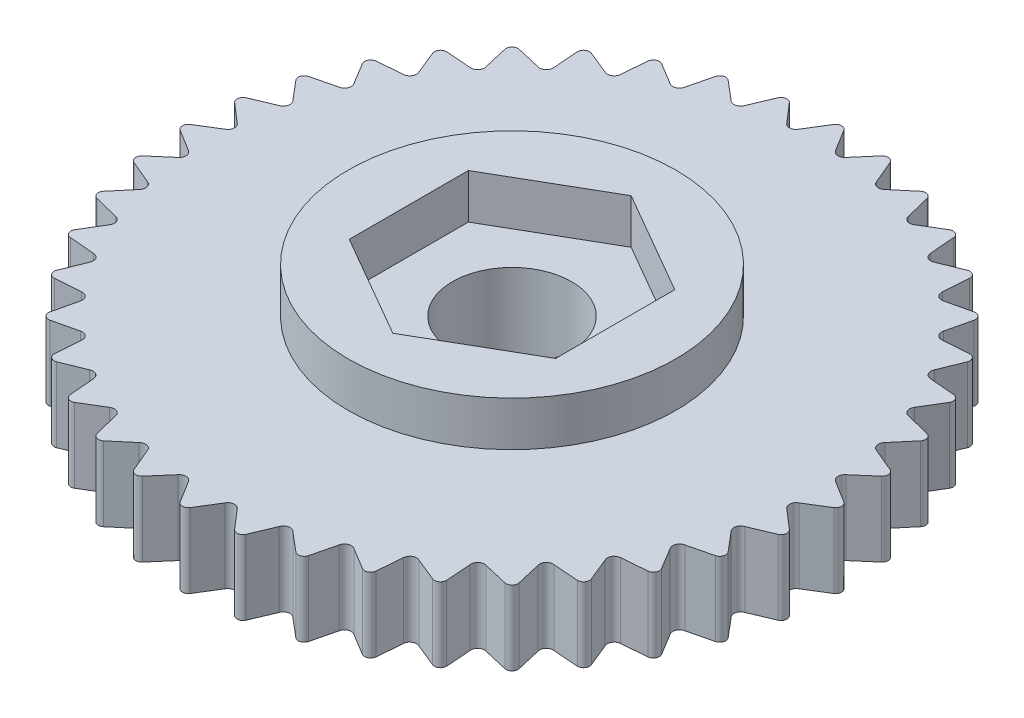
from build123d import *

# Parameters (mm, degrees)
SKETCH1_R           = 5.5
BOSS_EXTRUDE1_DEPTH = 2.5
SKETCH2_R           = 5.5
BOSS_EXTRUDE2_DEPTH = 4
SKETCH3_R           = 2.0025
BOSS_EXTRUDE3_DEPTH = 2.5


with BuildPart() as part:
    # Sketch1 → Boss-Extrude1 (new body)
    with BuildSketch(Plane(origin=(0, 0, 0), x_dir=(1, 0, 0), z_dir=(0, 1, 0))):
        with BuildLine():
            ThreePointArc((0.168753863, 10.978113748), (0, 11.07041569), (-0.168753863, 10.978113748))
            Line((-0.168753863, 10.978113748), (-0.617006311, 10.255915893))
            ThreePointArc((-0.617006311, 10.255915893), (-0.623950042, 10.243921028), (-0.63161743, 10.232375321))
            ThreePointArc((-0.63161743, 10.232375321), (-0.704256465, 10.166709543), (-0.797879357, 10.138018468))
            ThreePointArc((-0.797879357, 10.138018468), (-0.907657674, 10.156977793), (-0.994968777, 10.226169602))
            Line((-0.994968777, 10.226169602), (-1.550679129, 10.869353871))
            ThreePointArc((-1.550679129, 10.869353871), (-1.731794556, 10.934120503), (-1.884031574, 10.816556031))
            Line((-1.884031574, 10.816556031), (-2.213788656, 10.033127497))
            ThreePointArc((-2.213788656, 10.033127497), (-2.218770487, 10.02019407), (-2.224537331, 10.007591067))
            ThreePointArc((-2.224537331, 10.007591067), (-2.286009668, 9.931370495), (-2.373991634, 9.888386807))
            ThreePointArc((-2.373991634, 9.888386807), (-2.48538429, 9.889939599), (-2.582444431, 9.944621076))
            Line((-2.582444431, 9.944621076), (-3.231929254, 10.492954429))
            ThreePointArc((-3.231929254, 10.492954429), (-3.420946583, 10.52859098), (-3.552918175, 10.388658806))
            Line((-3.552918175, 10.388658806), (-3.756060176, 9.563290205))
            ThreePointArc((-3.756060176, 9.563290205), (-3.75895744, 9.549736679), (-3.76268174, 9.536386707))
            ThreePointArc((-3.76268174, 9.536386707), (-3.811473726, 9.451488144), (-3.891648358, 9.395270245))
            ThreePointArc((-3.891648358, 9.395270245), (-4.001912495, 9.37937827), (-4.106331733, 9.418202975))
            Line((-4.106331733, 9.418202975), (-4.833598554, 9.858183624))
            ThreePointArc((-4.833598554, 9.858183624), (-5.025863551, 9.863812605), (-5.13432014, 9.704958323))
            Line((-5.13432014, 9.704958323), (-5.20584503, 8.857972969))
            ThreePointArc((-5.20584503, 8.857972969), (-5.206586385, 8.844133078), (-5.208176436, 8.830364857))
            ThreePointArc((-5.208176436, 8.830364857), (-5.243086651, 8.738878788), (-5.313479783, 8.670810949))
            ThreePointArc((-5.313479783, 8.670810949), (-5.419900334, 8.637865519), (-5.529107519, 8.65987746))
            Line((-5.529107519, 8.65987746), (-6.316248616, 8.980671621))
            ThreePointArc((-6.316248616, 8.980671621), (-6.507027079, 8.956154428), (-6.589298102, 8.782289557))
            Line((-6.589298102, 8.782289557), (-6.527444702, 7.93454304))
            ThreePointArc((-6.527444702, 7.93454304), (-6.526011893, 7.920757568), (-6.525428545, 7.906910117))
            ThreePointArc((-6.525428545, 7.906910117), (-6.545597382, 7.811089234), (-6.604475702, 7.73284751))
            ThreePointArc((-6.604475702, 7.73284751), (-6.704432238, 7.683659851), (-6.815738329, 7.688317022))
            Line((-6.815738329, 7.688317022), (-7.643371675, 7.882025677))
            ThreePointArc((-7.643371675, 7.882025677), (-7.827966005, 7.827966005), (-7.882025677, 7.643371675))
            Line((-7.882025677, 7.643371675), (-7.688317022, 6.815738329))
            ThreePointArc((-7.688317022, 6.815738329), (-7.68474533, 6.802346719), (-7.682002945, 6.78876101))
            ThreePointArc((-7.682002945, 6.78876101), (-7.686933782, 6.690964738), (-7.73284751, 6.604475702))
            ThreePointArc((-7.73284751, 6.604475702), (-7.823878771, 6.540256977), (-7.93454304, 6.527444702))
            Line((-7.93454304, 6.527444702), (-8.782289557, 6.589298102))
            ThreePointArc((-8.782289557, 6.589298102), (-8.956154428, 6.507027079), (-8.980671621, 6.316248616))
            Line((-8.980671621, 6.316248616), (-8.65987746, 5.529107519))
            ThreePointArc((-8.65987746, 5.529107519), (-8.654254833, 5.516439518), (-8.649420938, 5.503450075))
            ThreePointArc((-8.649420938, 5.503450075), (-8.638992361, 5.406086486), (-8.670810949, 5.313479783))
            ThreePointArc((-8.670810949, 5.313479783), (-8.750675441, 5.235811271), (-8.857972969, 5.20584503))
            Line((-8.857972969, 5.20584503), (-9.704958323, 5.13432014))
            ThreePointArc((-9.704958323, 5.13432014), (-9.863812605, 5.025863551), (-9.858183624, 4.833598554))
            Line((-9.858183624, 4.833598554), (-9.418202975, 4.106331733))
            ThreePointArc((-9.418202975, 4.106331733), (-9.41066786, 4.094699269), (-9.403861482, 4.082625935))
            ThreePointArc((-9.403861482, 4.082625935), (-9.378330277, 3.988092441), (-9.395270245, 3.891648358))
            ThreePointArc((-9.395270245, 3.891648358), (-9.462001441, 3.802442515), (-9.563290205, 3.756060176))
            Line((-9.563290205, 3.756060176), (-10.388658806, 3.552918175))
            ThreePointArc((-10.388658806, 3.552918175), (-10.52859098, 3.420946583), (-10.492954429, 3.231929254))
            Line((-10.492954429, 3.231929254), (-9.944621076, 2.582444431))
            ThreePointArc((-9.944621076, 2.582444431), (-9.935359013, 2.572133934), (-9.926747746, 2.561273995))
            ThreePointArc((-9.926747746, 2.561273995), (-9.886742576, 2.471898326), (-9.888386807, 2.373991634))
            ThreePointArc((-9.888386807, 2.373991634), (-9.940341563, 2.275445004), (-10.033127497, 2.213788656))
            Line((-10.033127497, 2.213788656), (-10.816556031, 1.884031574))
            ThreePointArc((-10.816556031, 1.884031574), (-10.934120503, 1.731794556), (-10.869353871, 1.550679129))
            Line((-10.869353871, 1.550679129), (-10.226169602, 0.994968777))
            ThreePointArc((-10.226169602, 0.994968777), (-10.215408652, 0.986234125), (-10.205204536, 0.976854988))
            ThreePointArc((-10.205204536, 0.976854988), (-10.151710461, 0.89483787), (-10.138018468, 0.797879357))
            ThreePointArc((-10.138018468, 0.797879357), (-10.173917485, 0.692418485), (-10.255915893, 0.617006311))
            Line((-10.255915893, 0.617006311), (-10.978113748, 0.168753863))
            ThreePointArc((-10.978113748, 0.168753863), (-11.07041569, 0), (-10.978113748, -0.168753863))
            Line((-10.978113748, -0.168753863), (-10.255915893, -0.617006311))
            ThreePointArc((-10.255915893, -0.617006311), (-10.243921028, -0.623950042), (-10.232375321, -0.63161743))
            ThreePointArc((-10.232375321, -0.63161743), (-10.166709543, -0.704256465), (-10.138018468, -0.797879357))
            ThreePointArc((-10.138018468, -0.797879357), (-10.156977793, -0.907657674), (-10.226169602, -0.994968777))
            Line((-10.226169602, -0.994968777), (-10.869353871, -1.550679129))
            ThreePointArc((-10.869353871, -1.550679129), (-10.934120503, -1.731794556), (-10.816556031, -1.884031574))
            Line((-10.816556031, -1.884031574), (-10.033127497, -2.213788656))
            ThreePointArc((-10.033127497, -2.213788656), (-10.02019407, -2.218770487), (-10.007591067, -2.224537331))
            ThreePointArc((-10.007591067, -2.224537331), (-9.931370495, -2.286009668), (-9.888386807, -2.373991634))
            ThreePointArc((-9.888386807, -2.373991634), (-9.889939599, -2.48538429), (-9.944621076, -2.582444431))
            Line((-9.944621076, -2.582444431), (-10.492954429, -3.231929254))
            ThreePointArc((-10.492954429, -3.231929254), (-10.52859098, -3.420946583), (-10.388658806, -3.552918175))
            Line((-10.388658806, -3.552918175), (-9.563290205, -3.756060176))
            ThreePointArc((-9.563290205, -3.756060176), (-9.549736679, -3.75895744), (-9.536386707, -3.76268174))
            ThreePointArc((-9.536386707, -3.76268174), (-9.451488144, -3.811473726), (-9.395270245, -3.891648358))
            ThreePointArc((-9.395270245, -3.891648358), (-9.37937827, -4.001912495), (-9.418202975, -4.106331733))
            Line((-9.418202975, -4.106331733), (-9.858183624, -4.833598554))
            ThreePointArc((-9.858183624, -4.833598554), (-9.863812605, -5.025863551), (-9.704958323, -5.13432014))
            Line((-9.704958323, -5.13432014), (-8.857972969, -5.20584503))
            ThreePointArc((-8.857972969, -5.20584503), (-8.844133078, -5.206586385), (-8.830364857, -5.208176436))
            ThreePointArc((-8.830364857, -5.208176436), (-8.738878788, -5.243086651), (-8.670810949, -5.313479783))
            ThreePointArc((-8.670810949, -5.313479783), (-8.637865519, -5.419900334), (-8.65987746, -5.529107519))
            Line((-8.65987746, -5.529107519), (-8.980671621, -6.316248616))
            ThreePointArc((-8.980671621, -6.316248616), (-8.956154428, -6.507027079), (-8.782289557, -6.589298102))
            Line((-8.782289557, -6.589298102), (-7.93454304, -6.527444702))
            ThreePointArc((-7.93454304, -6.527444702), (-7.920757568, -6.526011893), (-7.906910117, -6.525428545))
            ThreePointArc((-7.906910117, -6.525428545), (-7.811089234, -6.545597382), (-7.73284751, -6.604475702))
            ThreePointArc((-7.73284751, -6.604475702), (-7.683659851, -6.704432238), (-7.688317022, -6.815738329))
            Line((-7.688317022, -6.815738329), (-7.882025677, -7.643371675))
            ThreePointArc((-7.882025677, -7.643371675), (-7.827966005, -7.827966005), (-7.643371675, -7.882025677))
            Line((-7.643371675, -7.882025677), (-6.815738329, -7.688317022))
            ThreePointArc((-6.815738329, -7.688317022), (-6.802346719, -7.68474533), (-6.78876101, -7.682002945))
            ThreePointArc((-6.78876101, -7.682002945), (-6.690964738, -7.686933782), (-6.604475702, -7.73284751))
            ThreePointArc((-6.604475702, -7.73284751), (-6.540256977, -7.823878771), (-6.527444702, -7.93454304))
            Line((-6.527444702, -7.93454304), (-6.589298102, -8.782289557))
            ThreePointArc((-6.589298102, -8.782289557), (-6.507027079, -8.956154428), (-6.316248616, -8.980671621))
            Line((-6.316248616, -8.980671621), (-5.529107519, -8.65987746))
            ThreePointArc((-5.529107519, -8.65987746), (-5.516439518, -8.654254833), (-5.503450075, -8.649420938))
            ThreePointArc((-5.503450075, -8.649420938), (-5.406086486, -8.638992361), (-5.313479783, -8.670810949))
            ThreePointArc((-5.313479783, -8.670810949), (-5.235811271, -8.750675441), (-5.20584503, -8.857972969))
            Line((-5.20584503, -8.857972969), (-5.13432014, -9.704958323))
            ThreePointArc((-5.13432014, -9.704958323), (-5.025863551, -9.863812605), (-4.833598554, -9.858183624))
            Line((-4.833598554, -9.858183624), (-4.106331733, -9.418202975))
            ThreePointArc((-4.106331733, -9.418202975), (-4.094699269, -9.41066786), (-4.082625935, -9.403861482))
            ThreePointArc((-4.082625935, -9.403861482), (-3.988092441, -9.378330277), (-3.891648358, -9.395270245))
            ThreePointArc((-3.891648358, -9.395270245), (-3.802442515, -9.462001441), (-3.756060176, -9.563290205))
            Line((-3.756060176, -9.563290205), (-3.552918175, -10.388658806))
            ThreePointArc((-3.552918175, -10.388658806), (-3.420946583, -10.52859098), (-3.231929254, -10.492954429))
            Line((-3.231929254, -10.492954429), (-2.582444431, -9.944621076))
            ThreePointArc((-2.582444431, -9.944621076), (-2.572133934, -9.935359013), (-2.561273995, -9.926747746))
            ThreePointArc((-2.561273995, -9.926747746), (-2.471898326, -9.886742576), (-2.373991634, -9.888386807))
            ThreePointArc((-2.373991634, -9.888386807), (-2.275445004, -9.940341563), (-2.213788656, -10.033127497))
            Line((-2.213788656, -10.033127497), (-1.884031574, -10.816556031))
            ThreePointArc((-1.884031574, -10.816556031), (-1.731794556, -10.934120503), (-1.550679129, -10.869353871))
            Line((-1.550679129, -10.869353871), (-0.994968777, -10.226169602))
            ThreePointArc((-0.994968777, -10.226169602), (-0.986234125, -10.215408652), (-0.976854988, -10.205204536))
            ThreePointArc((-0.976854988, -10.205204536), (-0.89483787, -10.151710461), (-0.797879357, -10.138018468))
            ThreePointArc((-0.797879357, -10.138018468), (-0.692418485, -10.173917485), (-0.617006311, -10.255915893))
            Line((-0.617006311, -10.255915893), (-0.168753863, -10.978113748))
            ThreePointArc((-0.168753863, -10.978113748), (0, -11.07041569), (0.168753863, -10.978113748))
            Line((0.168753863, -10.978113748), (0.617006311, -10.255915893))
            ThreePointArc((0.617006311, -10.255915893), (0.623950042, -10.243921028), (0.63161743, -10.232375321))
            ThreePointArc((0.63161743, -10.232375321), (0.704256465, -10.166709543), (0.797879357, -10.138018468))
            ThreePointArc((0.797879357, -10.138018468), (0.907657674, -10.156977793), (0.994968777, -10.226169602))
            Line((0.994968777, -10.226169602), (1.550679129, -10.869353871))
            ThreePointArc((1.550679129, -10.869353871), (1.731794556, -10.934120503), (1.884031574, -10.816556031))
            Line((1.884031574, -10.816556031), (2.213788656, -10.033127497))
            ThreePointArc((2.213788656, -10.033127497), (2.218770487, -10.02019407), (2.224537331, -10.007591067))
            ThreePointArc((2.224537331, -10.007591067), (2.286009668, -9.931370495), (2.373991634, -9.888386807))
            ThreePointArc((2.373991634, -9.888386807), (2.48538429, -9.889939599), (2.582444431, -9.944621076))
            Line((2.582444431, -9.944621076), (3.231929254, -10.492954429))
            ThreePointArc((3.231929254, -10.492954429), (3.420946583, -10.52859098), (3.552918175, -10.388658806))
            Line((3.552918175, -10.388658806), (3.756060176, -9.563290205))
            ThreePointArc((3.756060176, -9.563290205), (3.75895744, -9.549736679), (3.76268174, -9.536386707))
            ThreePointArc((3.76268174, -9.536386707), (3.811473726, -9.451488144), (3.891648358, -9.395270245))
            ThreePointArc((3.891648358, -9.395270245), (4.001912495, -9.37937827), (4.106331733, -9.418202975))
            Line((4.106331733, -9.418202975), (4.833598554, -9.858183624))
            ThreePointArc((4.833598554, -9.858183624), (5.025863551, -9.863812605), (5.13432014, -9.704958323))
            Line((5.13432014, -9.704958323), (5.20584503, -8.857972969))
            ThreePointArc((5.20584503, -8.857972969), (5.206586385, -8.844133078), (5.208176436, -8.830364857))
            ThreePointArc((5.208176436, -8.830364857), (5.243086651, -8.738878788), (5.313479783, -8.670810949))
            ThreePointArc((5.313479783, -8.670810949), (5.419900334, -8.637865519), (5.529107519, -8.65987746))
            Line((5.529107519, -8.65987746), (6.316248616, -8.980671621))
            ThreePointArc((6.316248616, -8.980671621), (6.507027079, -8.956154428), (6.589298102, -8.782289557))
            Line((6.589298102, -8.782289557), (6.527444702, -7.93454304))
            ThreePointArc((6.527444702, -7.93454304), (6.526011893, -7.920757568), (6.525428545, -7.906910117))
            ThreePointArc((6.525428545, -7.906910117), (6.545597382, -7.811089234), (6.604475702, -7.73284751))
            ThreePointArc((6.604475702, -7.73284751), (6.704432238, -7.683659851), (6.815738329, -7.688317022))
            Line((6.815738329, -7.688317022), (7.643371675, -7.882025677))
            ThreePointArc((7.643371675, -7.882025677), (7.827966005, -7.827966005), (7.882025677, -7.643371675))
            Line((7.882025677, -7.643371675), (7.688317022, -6.815738329))
            ThreePointArc((7.688317022, -6.815738329), (7.68474533, -6.802346719), (7.682002945, -6.78876101))
            ThreePointArc((7.682002945, -6.78876101), (7.686933782, -6.690964738), (7.73284751, -6.604475702))
            ThreePointArc((7.73284751, -6.604475702), (7.823878771, -6.540256977), (7.93454304, -6.527444702))
            Line((7.93454304, -6.527444702), (8.782289557, -6.589298102))
            ThreePointArc((8.782289557, -6.589298102), (8.956154428, -6.507027079), (8.980671621, -6.316248616))
            Line((8.980671621, -6.316248616), (8.65987746, -5.529107519))
            ThreePointArc((8.65987746, -5.529107519), (8.654254833, -5.516439518), (8.649420938, -5.503450075))
            ThreePointArc((8.649420938, -5.503450075), (8.638992361, -5.406086486), (8.670810949, -5.313479783))
            ThreePointArc((8.670810949, -5.313479783), (8.750675441, -5.235811271), (8.857972969, -5.20584503))
            Line((8.857972969, -5.20584503), (9.704958323, -5.13432014))
            ThreePointArc((9.704958323, -5.13432014), (9.863812605, -5.025863551), (9.858183624, -4.833598554))
            Line((9.858183624, -4.833598554), (9.418202975, -4.106331733))
            ThreePointArc((9.418202975, -4.106331733), (9.41066786, -4.094699269), (9.403861482, -4.082625935))
            ThreePointArc((9.403861482, -4.082625935), (9.378330277, -3.988092441), (9.395270245, -3.891648358))
            ThreePointArc((9.395270245, -3.891648358), (9.462001441, -3.802442515), (9.563290205, -3.756060176))
            Line((9.563290205, -3.756060176), (10.388658806, -3.552918175))
            ThreePointArc((10.388658806, -3.552918175), (10.52859098, -3.420946583), (10.492954429, -3.231929254))
            Line((10.492954429, -3.231929254), (9.944621076, -2.582444431))
            ThreePointArc((9.944621076, -2.582444431), (9.935359013, -2.572133934), (9.926747746, -2.561273995))
            ThreePointArc((9.926747746, -2.561273995), (9.886742576, -2.471898326), (9.888386807, -2.373991634))
            ThreePointArc((9.888386807, -2.373991634), (9.940341563, -2.275445004), (10.033127497, -2.213788656))
            Line((10.033127497, -2.213788656), (10.816556031, -1.884031574))
            ThreePointArc((10.816556031, -1.884031574), (10.934120503, -1.731794556), (10.869353871, -1.550679129))
            Line((10.869353871, -1.550679129), (10.226169602, -0.994968777))
            ThreePointArc((10.226169602, -0.994968777), (10.215408652, -0.986234125), (10.205204536, -0.976854988))
            ThreePointArc((10.205204536, -0.976854988), (10.151710461, -0.89483787), (10.138018468, -0.797879357))
            ThreePointArc((10.138018468, -0.797879357), (10.173917485, -0.692418485), (10.255915893, -0.617006311))
            Line((10.255915893, -0.617006311), (10.978113748, -0.168753863))
            ThreePointArc((10.978113748, -0.168753863), (11.07041569, 0), (10.978113748, 0.168753863))
            Line((10.978113748, 0.168753863), (10.255915893, 0.617006311))
            ThreePointArc((10.255915893, 0.617006311), (10.243921028, 0.623950042), (10.232375321, 0.63161743))
            ThreePointArc((10.232375321, 0.63161743), (10.166709543, 0.704256465), (10.138018468, 0.797879357))
            ThreePointArc((10.138018468, 0.797879357), (10.156977793, 0.907657674), (10.226169602, 0.994968777))
            Line((10.226169602, 0.994968777), (10.869353871, 1.550679129))
            ThreePointArc((10.869353871, 1.550679129), (10.934120503, 1.731794556), (10.816556031, 1.884031574))
            Line((10.816556031, 1.884031574), (10.033127497, 2.213788656))
            ThreePointArc((10.033127497, 2.213788656), (10.02019407, 2.218770487), (10.007591067, 2.224537331))
            ThreePointArc((10.007591067, 2.224537331), (9.931370495, 2.286009668), (9.888386807, 2.373991634))
            ThreePointArc((9.888386807, 2.373991634), (9.889939599, 2.48538429), (9.944621076, 2.582444431))
            Line((9.944621076, 2.582444431), (10.492954429, 3.231929254))
            ThreePointArc((10.492954429, 3.231929254), (10.52859098, 3.420946583), (10.388658806, 3.552918175))
            Line((10.388658806, 3.552918175), (9.563290205, 3.756060176))
            ThreePointArc((9.563290205, 3.756060176), (9.549736679, 3.75895744), (9.536386707, 3.76268174))
            ThreePointArc((9.536386707, 3.76268174), (9.451488144, 3.811473726), (9.395270245, 3.891648358))
            ThreePointArc((9.395270245, 3.891648358), (9.37937827, 4.001912495), (9.418202975, 4.106331733))
            Line((9.418202975, 4.106331733), (9.858183624, 4.833598554))
            ThreePointArc((9.858183624, 4.833598554), (9.863812605, 5.025863551), (9.704958323, 5.13432014))
            Line((9.704958323, 5.13432014), (8.857972969, 5.20584503))
            ThreePointArc((8.857972969, 5.20584503), (8.844133078, 5.206586385), (8.830364857, 5.208176436))
            ThreePointArc((8.830364857, 5.208176436), (8.738878788, 5.243086651), (8.670810949, 5.313479783))
            ThreePointArc((8.670810949, 5.313479783), (8.637865519, 5.419900334), (8.65987746, 5.529107519))
            Line((8.65987746, 5.529107519), (8.980671621, 6.316248616))
            ThreePointArc((8.980671621, 6.316248616), (8.956154428, 6.507027079), (8.782289557, 6.589298102))
            Line((8.782289557, 6.589298102), (7.93454304, 6.527444702))
            ThreePointArc((7.93454304, 6.527444702), (7.920757568, 6.526011893), (7.906910117, 6.525428545))
            ThreePointArc((7.906910117, 6.525428545), (7.811089234, 6.545597382), (7.73284751, 6.604475702))
            ThreePointArc((7.73284751, 6.604475702), (7.683659851, 6.704432238), (7.688317022, 6.815738329))
            Line((7.688317022, 6.815738329), (7.882025677, 7.643371675))
            ThreePointArc((7.882025677, 7.643371675), (7.827966005, 7.827966005), (7.643371675, 7.882025677))
            Line((7.643371675, 7.882025677), (6.815738329, 7.688317022))
            ThreePointArc((6.815738329, 7.688317022), (6.802346719, 7.68474533), (6.78876101, 7.682002945))
            ThreePointArc((6.78876101, 7.682002945), (6.690964738, 7.686933782), (6.604475702, 7.73284751))
            ThreePointArc((6.604475702, 7.73284751), (6.540256977, 7.823878771), (6.527444702, 7.93454304))
            Line((6.527444702, 7.93454304), (6.589298102, 8.782289557))
            ThreePointArc((6.589298102, 8.782289557), (6.507027079, 8.956154428), (6.316248616, 8.980671621))
            Line((6.316248616, 8.980671621), (5.529107519, 8.65987746))
            ThreePointArc((5.529107519, 8.65987746), (5.516439518, 8.654254833), (5.503450075, 8.649420938))
            ThreePointArc((5.503450075, 8.649420938), (5.406086486, 8.638992361), (5.313479783, 8.670810949))
            ThreePointArc((5.313479783, 8.670810949), (5.235811271, 8.750675441), (5.20584503, 8.857972969))
            Line((5.20584503, 8.857972969), (5.13432014, 9.704958323))
            ThreePointArc((5.13432014, 9.704958323), (5.025863551, 9.863812605), (4.833598554, 9.858183624))
            Line((4.833598554, 9.858183624), (4.106331733, 9.418202975))
            ThreePointArc((4.106331733, 9.418202975), (4.094699269, 9.41066786), (4.082625935, 9.403861482))
            ThreePointArc((4.082625935, 9.403861482), (3.988092441, 9.378330277), (3.891648358, 9.395270245))
            ThreePointArc((3.891648358, 9.395270245), (3.802442515, 9.462001441), (3.756060176, 9.563290205))
            Line((3.756060176, 9.563290205), (3.552918175, 10.388658806))
            ThreePointArc((3.552918175, 10.388658806), (3.420946583, 10.52859098), (3.231929254, 10.492954429))
            Line((3.231929254, 10.492954429), (2.582444431, 9.944621076))
            ThreePointArc((2.582444431, 9.944621076), (2.572133934, 9.935359013), (2.561273995, 9.926747746))
            ThreePointArc((2.561273995, 9.926747746), (2.471898326, 9.886742576), (2.373991634, 9.888386807))
            ThreePointArc((2.373991634, 9.888386807), (2.275445004, 9.940341563), (2.213788656, 10.033127497))
            Line((2.213788656, 10.033127497), (1.884031574, 10.816556031))
            ThreePointArc((1.884031574, 10.816556031), (1.731794556, 10.934120503), (1.550679129, 10.869353871))
            Line((1.550679129, 10.869353871), (0.994968777, 10.226169602))
            ThreePointArc((0.994968777, 10.226169602), (0.986234125, 10.215408652), (0.976854988, 10.205204536))
            ThreePointArc((0.976854988, 10.205204536), (0.89483787, 10.151710461), (0.797879357, 10.138018468))
            ThreePointArc((0.797879357, 10.138018468), (0.692418485, 10.173917485), (0.617006311, 10.255915893))
            Line((0.617006311, 10.255915893), (0.168753863, 10.978113748))
        make_face()
        Circle(SKETCH1_R, mode=Mode.SUBTRACT)
    extrude(amount=BOSS_EXTRUDE1_DEPTH)

    # Sketch2 → Boss-Extrude2 (add)
    with BuildSketch(Plane(origin=(0, 0, 0), x_dir=(1, 0, 0), z_dir=(0, 1, 0))):
        Circle(SKETCH2_R)
        Polygon((0, 4.0025), (-3.466266679, 2.00125), (-3.466266679, -2.00125), (0, -4.0025), (3.466266679, -2.00125), (3.466266679, 2.00125), align=None, mode=Mode.SUBTRACT)
    extrude(amount=BOSS_EXTRUDE2_DEPTH)

    # Sketch3 → Boss-Extrude3 (add)
    with BuildSketch(Plane(origin=(0, 0, 0), x_dir=(1, 0, 0), z_dir=(0, 1, 0))):
        Polygon((0, 4.0025), (-3.466266679, 2.00125), (-3.466266679, -2.00125), (0, -4.0025), (3.466266679, -2.00125), (3.466266679, 2.00125), align=None)
        Circle(SKETCH3_R, mode=Mode.SUBTRACT)
    extrude(amount=BOSS_EXTRUDE3_DEPTH)


solid = part.part
